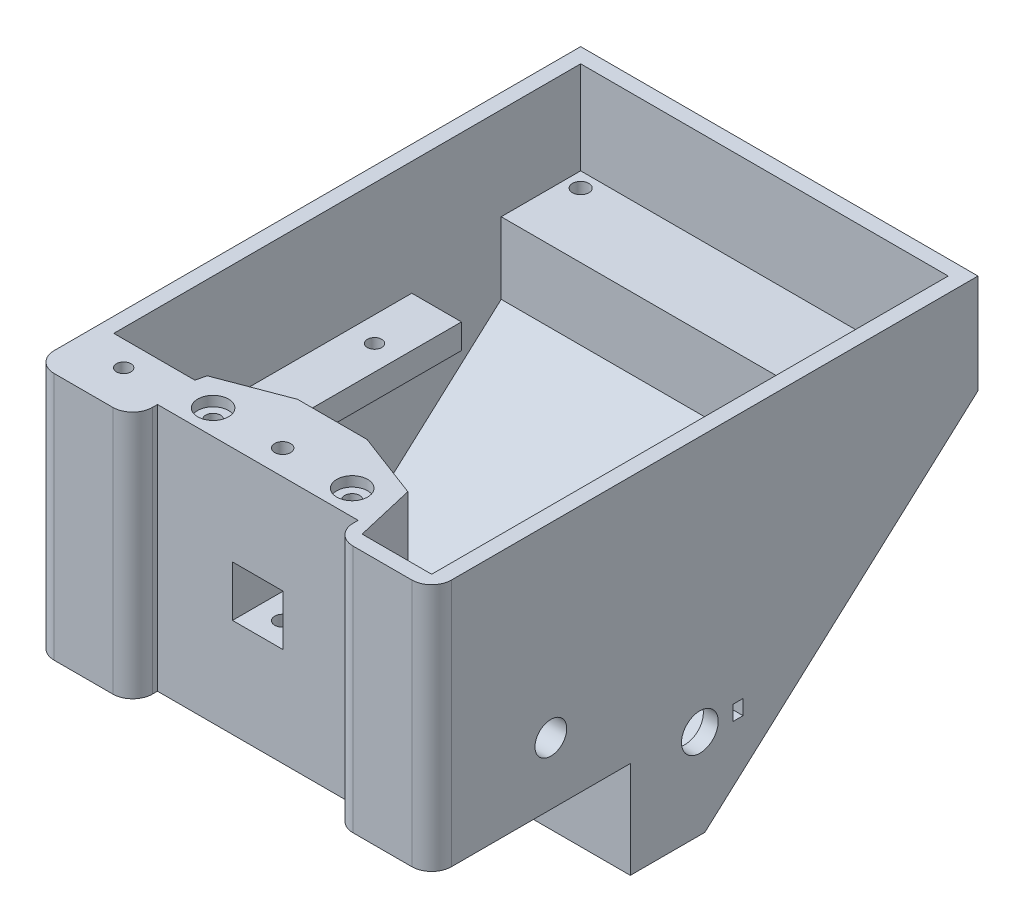
from build123d import *

# Parameters (mm, degrees)
BOSS_EXTRUDE1_DEPTH = 80
SHELL1_T            = -3
SKETCH3_W           = 46
SKETCH3_H           = 47
BOSS_EXTRUDE2_DEPTH = 17
SKETCH4_W           = 10.2
SKETCH4_H           = 10.2
CUT_EXTRUDE1_DEPTH  = 20
SKETCH6_W           = 15
SKETCH6_H           = 12.8
CUT_EXTRUDE2_DEPTH  = 3
SKETCH7_W           = 40.4
SKETCH7_H           = 50
CUT_EXTRUDE3_DEPTH  = 5
FILLET1_R           = 4
CUT_EXTRUDE7_DEPTH  = 47
SKETCH13_R          = 1.5
CUT_EXTRUDE8_DEPTH  = 25
SKETCH14_R          = 3.1
CUT_EXTRUDE9_DEPTH  = 2
SKETCH17_W          = 45
SKETCH17_H          = 5
BOSS_EXTRUDE5_DEPTH = 74
CUT_EXTRUDE10_REACH = 126.093
SKETCH18_W          = 54
SKETCH18_H          = 45
CUT_EXTRUDE11_REACH = 126.093
SKETCH19_R          = 1.45
BOSS_EXTRUDE6_DEPTH = 47
SKETCH22_R          = 1.45
CUT_EXTRUDE12_DEPTH = 135.415364765
CUT_EXTRUDE13_REACH = 126.857
SKETCH24_R          = 3.7
SKETCH24_W          = 2
SKETCH24_H          = 3
BOSS_EXTRUDE7_DEPTH = 74
SKETCH27_R          = 1.65
CUT_EXTRUDE14_DEPTH = 10
CUT_EXTRUDE15_START = -3
CUT_EXTRUDE15_DEPTH = 32
CUT_EXTRUDE16_DEPTH = 30
BOSS_EXTRUDE8_DEPTH = 20
SKETCH31_R          = 1.5
CUT_EXTRUDE17_DEPTH = 123.649786567
CUT_EXTRUDE18_DEPTH = 15
CUT_EXTRUDE19_REACH = 126.093
SKETCH33_W          = 10
SKETCH33_H          = 5
SKETCH34_R          = 1.6
CUT_EXTRUDE20_DEPTH = 135.415364765
CUT_EXTRUDE22_DEPTH = 14
CUT_EXTRUDE23_REACH = 126.857
SKETCH37_R          = 3.2
SKETCH38_W          = 10
SKETCH38_H          = 18.980735551
SKETCH38_R          = 3.2
BOSS_EXTRUDE9_DEPTH = 3


with BuildPart() as part:
    # Sketch2 → Boss-Extrude1 (new body)
    with BuildSketch(Plane(origin=(0, 0, 0), x_dir=(0, 0, -1), z_dir=(1, 0, 0))):
        Polygon((-27.320490368, 20.998248687), (-27.320490368, -29.001751313), (12.679509632, -29.001751313), (12.679509632, -48.511383538), (27.679509632, -48.511383538), (82.679509632, 0.998248687), (82.679509632, 20.998248687), align=None)
    extrude(amount=BOSS_EXTRUDE1_DEPTH)

    # Shell1
    shell1_openings = [part.faces().sort_by_distance(p)[0] for p in [
        (40, 20.998248687, -27.679509632),
    ]]
    offset(amount=SHELL1_T, openings=shell1_openings, kind=Kind.INTERSECTION)

    # Sketch3 → Boss-Extrude2 (add)
    with BuildSketch(Plane(origin=(0, 0, 24.320490368), x_dir=(-1, 0, 0), z_dir=(0, 0, -1))):
        with Locations((-40, -2.501751313)):
            Rectangle(SKETCH3_W, SKETCH3_H)
    extrude(amount=BOSS_EXTRUDE2_DEPTH)

    # Sketch4 → Cut-Extrude1 (cut)
    with BuildSketch(Plane.XY.offset(27.320490368)):
        with Locations((40, -4.001751313)):
            Rectangle(SKETCH4_W, SKETCH4_H)
    extrude(amount=-CUT_EXTRUDE1_DEPTH, mode=Mode.SUBTRACT)

    # Sketch6 → Cut-Extrude2 (cut)
    with BuildSketch(Plane.XZ.offset(29.001751313)):
        with Locations((51.5, 0.920490368)):
            Rectangle(SKETCH6_W, SKETCH6_H)
        with Locations((28.5, 0.920490368)):
            Rectangle(SKETCH6_W, SKETCH6_H)
    extrude(amount=-CUT_EXTRUDE2_DEPTH, mode=Mode.SUBTRACT)

    # Sketch7 → Cut-Extrude3 (cut)
    with BuildSketch(Plane.XY.offset(27.320490368)):
        with Locations((40, -4.001751313)):
            Rectangle(SKETCH7_W, SKETCH7_H)
    extrude(amount=-CUT_EXTRUDE3_DEPTH, mode=Mode.SUBTRACT)

    # Fillet1
    fillet1_edges = [part.edges().sort_by_distance(p)[0] for p in [
        (19.8, -4.001751313, 27.320490368),
        (60.2, -4.001751313, 27.320490368),
        (80, -4.001751313, 27.320490368),
        (0, -4.001751313, 27.320490368),
    ]]
    fillet(fillet1_edges, radius=FILLET1_R)

    # Sketch12 → Cut-Extrude7 (cut)
    with BuildSketch(Plane(origin=(0, 20.998248687, 0), x_dir=(1, 0, 0), z_dir=(0, 1, 0))):
        Polygon((33, -7.320490368), (19.8, -12.320490368), (17, -24.320490368), (17, -7.320490368), align=None)
        Polygon((47, -7.320490368), (63, -7.320490368), (63, -24.320490368), (60.2, -12.320490368), align=None)
    extrude(amount=-CUT_EXTRUDE7_DEPTH, mode=Mode.SUBTRACT)

    # Sketch13 → Cut-Extrude8 (cut)
    with BuildSketch(Plane(origin=(0, 20.998248687, 0), x_dir=(1, 0, 0), z_dir=(0, 1, 0))):
        with Locations(Location((26, -17.320490368, 0), (0, 0, 270))):
            Circle(SKETCH13_R)
        with Locations(Location((54, -17.320490368, 0), (0, 0, 270))):
            Circle(SKETCH13_R)
    extrude(amount=-CUT_EXTRUDE8_DEPTH, mode=Mode.SUBTRACT)

    # Sketch14 → Cut-Extrude9 (cut)
    with BuildSketch(Plane(origin=(0, 20.998248687, 0), x_dir=(1, 0, 0), z_dir=(0, 1, 0))):
        with Locations(Location((26, -17.320490368, 0), (0, 0, 270))):
            Circle(SKETCH14_R)
        with Locations(Location((54, -17.320490368, 0), (0, 0, 270))):
            Circle(SKETCH14_R)
    extrude(amount=-CUT_EXTRUDE9_DEPTH, mode=Mode.SUBTRACT)

    # Sketch17 → Boss-Extrude5 (add)
    with BuildSketch(Plane.ZY.offset(-77)):
        with Locations((-23.179509632, -4.501751313)):
            Rectangle(SKETCH17_W, SKETCH17_H)
    extrude(amount=BOSS_EXTRUDE5_DEPTH)

    # Sketch18 → Cut-Extrude10 (cut, up to next)
    with BuildSketch(Plane(origin=(0, -2.001751313, 0), x_dir=(1, 0, 0), z_dir=(0, 1, 0)), mode=Mode.PRIVATE) as cut_extrude10_sk1:
        with Locations((40, 23.179509632)):
            Rectangle(SKETCH18_W, SKETCH18_H)
    cut_extrude10_tool1 = extrude(cut_extrude10_sk1.sketch, amount=-CUT_EXTRUDE10_REACH, mode=Mode.PRIVATE) & part.part
    add(cut_extrude10_tool1.solids().sort_by_distance((40, -2.001751, -23.17951))[0], mode=Mode.SUBTRACT)

    # Sketch19 → Cut-Extrude11 (cut, up to next)
    with BuildSketch(Plane(origin=(0, -2.001751313, 0), x_dir=(1, 0, 0), z_dir=(0, 1, 0)), mode=Mode.PRIVATE) as cut_extrude11_sk1:
        with Locations(Location((72, 37.179509632, 0), (0, 0, 270))):
            Circle(SKETCH19_R)
    cut_extrude11_tool1 = extrude(cut_extrude11_sk1.sketch, amount=-CUT_EXTRUDE11_REACH, mode=Mode.PRIVATE) & part.part
    # Sketch19 → Cut-Extrude11 (cut, up to next)
    with BuildSketch(Plane(origin=(0, -2.001751313, 0), x_dir=(1, 0, 0), z_dir=(0, 1, 0)), mode=Mode.PRIVATE) as cut_extrude11_sk2:
        with Locations(Location((72, 6.179509632, 0), (0, 0, 270))):
            Circle(SKETCH19_R)
    cut_extrude11_tool2 = extrude(cut_extrude11_sk2.sketch, amount=-CUT_EXTRUDE11_REACH, mode=Mode.PRIVATE) & part.part
    # Sketch19 → Cut-Extrude11 (cut, up to next)
    with BuildSketch(Plane(origin=(0, -2.001751313, 0), x_dir=(1, 0, 0), z_dir=(0, 1, 0)), mode=Mode.PRIVATE) as cut_extrude11_sk3:
        with Locations(Location((8, 33.179509632, 0), (0, 0, 270))):
            Circle(SKETCH19_R)
    cut_extrude11_tool3 = extrude(cut_extrude11_sk3.sketch, amount=-CUT_EXTRUDE11_REACH, mode=Mode.PRIVATE) & part.part
    # Sketch19 → Cut-Extrude11 (cut, up to next)
    with BuildSketch(Plane(origin=(0, -2.001751313, 0), x_dir=(1, 0, 0), z_dir=(0, 1, 0)), mode=Mode.PRIVATE) as cut_extrude11_sk4:
        with Locations(Location((8, 6.179509632, 0), (0, 0, 270))):
            Circle(SKETCH19_R)
    cut_extrude11_tool4 = extrude(cut_extrude11_sk4.sketch, amount=-CUT_EXTRUDE11_REACH, mode=Mode.PRIVATE) & part.part
    add(cut_extrude11_tool1.solids().sort_by_distance((72, -2.001751, -37.17951))[0], mode=Mode.SUBTRACT)
    add(cut_extrude11_tool2.solids().sort_by_distance((72, -2.001751, -6.17951))[0], mode=Mode.SUBTRACT)
    add(cut_extrude11_tool3.solids().sort_by_distance((8, -2.001751, -33.17951))[0], mode=Mode.SUBTRACT)
    add(cut_extrude11_tool4.solids().sort_by_distance((8, -2.001751, -6.17951))[0], mode=Mode.SUBTRACT)

    # Sketch21 → Boss-Extrude6 (add)
    with BuildSketch(Plane(origin=(0, -26.001751313, 0), x_dir=(1, 0, 0), z_dir=(0, 1, 0))):
        Polygon((3, -24.320490368), (3, -14.320490368), (19.333333333, -14.320490368), (17, -24.320490368), align=None)
    extrude(amount=BOSS_EXTRUDE6_DEPTH)

    # Sketch22 → Cut-Extrude12 (cut, through all)
    with BuildSketch(Plane(origin=(0, 20.998248687, 0), x_dir=(1, 0, 0), z_dir=(0, 1, 0))):
        with Locations(Location((10, -19.320490368, 0), (0, 0, 270))):
            Circle(SKETCH22_R)
    extrude(amount=-CUT_EXTRUDE12_DEPTH, mode=Mode.SUBTRACT)

    # Sketch24 → Cut-Extrude13 (cut, up to next)
    with BuildSketch(Plane(origin=(80, 0, 0), x_dir=(0, 0, -1), z_dir=(1, 0, 0)), mode=Mode.PRIVATE) as cut_extrude13_sk1:
        with Locations((26.679509632, -30.511383538)):
            Circle(SKETCH24_R)
    cut_extrude13_tool1 = extrude(cut_extrude13_sk1.sketch, amount=-CUT_EXTRUDE13_REACH, mode=Mode.PRIVATE) & part.part
    # Sketch24 → Cut-Extrude13 (cut, up to next)
    with BuildSketch(Plane(origin=(80, 0, 0), x_dir=(0, 0, -1), z_dir=(1, 0, 0)), mode=Mode.PRIVATE) as cut_extrude13_sk2:
        with Locations((34.379509632, -30.511383538)):
            Rectangle(SKETCH24_W, SKETCH24_H)
    cut_extrude13_tool2 = extrude(cut_extrude13_sk2.sketch, amount=-CUT_EXTRUDE13_REACH, mode=Mode.PRIVATE) & part.part
    add(cut_extrude13_tool1.solids().sort_by_distance((80, -30.511384, -26.67951))[0], mode=Mode.SUBTRACT)
    add(cut_extrude13_tool2.solids().sort_by_distance((80, -30.511384, -34.37951))[0], mode=Mode.SUBTRACT)

    # Sketch26 → Boss-Extrude7 (add)
    with BuildSketch(Plane(origin=(3, 0, 0), x_dir=(0, 0, -1), z_dir=(1, 0, 0))):
        Polygon((79.679509632, 2.334161996), (63.679509632, 2.334161996), (63.679509632, -12.068640106), align=None)
    extrude(amount=BOSS_EXTRUDE7_DEPTH)

    # Sketch27 → Cut-Extrude14 (cut)
    with BuildSketch(Plane(origin=(0, 2.334161996, 0), x_dir=(1, 0, 0), z_dir=(0, 1, 0))):
        with Locations(Location((6, 76.679509632, 0), (0, 0, 270))):
            Circle(SKETCH27_R)
        with Locations(Location((74, 76.679509632, 0), (0, 0, 270))):
            Circle(SKETCH27_R)
    extrude(amount=-CUT_EXTRUDE14_DEPTH, mode=Mode.SUBTRACT)

    # Sketch28 → Cut-Extrude15 (cut)
    with BuildSketch(Plane(origin=(0, 2.334161996, 0), x_dir=(1, 0, 0), z_dir=(0, 1, 0)).offset(CUT_EXTRUDE15_START)):
        Polygon((74, 79.929509632), (71.185417438, 78.304509632), (71.185417438, 75.054509632), (74, 73.429509632), (76.814582562, 75.054509632), (76.814582562, 78.304509632), align=None)
        Polygon((6, 73.429509632), (8.814582562, 75.054509632), (8.814582562, 78.304509632), (6, 79.929509632), (3.185417438, 78.304509632), (3.185417438, 75.054509632), align=None)
    extrude(amount=-CUT_EXTRUDE15_DEPTH, mode=Mode.SUBTRACT)

    # Sketch29 → Cut-Extrude16 (cut)
    with BuildSketch(Plane.XZ.offset(29.001751313)):
        Polygon((7.185417438, 17.695490368), (10, 16.070490368), (12.814582562, 17.695490368), (12.814582562, 20.945490368), (10, 22.570490368), (7.185417438, 20.945490368), align=None)
    extrude(amount=-CUT_EXTRUDE16_DEPTH, mode=Mode.SUBTRACT)

    # Sketch30 → Boss-Extrude8 (add)
    with BuildSketch(Plane(origin=(0, -26.001751313, 0), x_dir=(1, 0, 0), z_dir=(0, 1, 0))):
        Polygon((77, -24.320490368), (63, -24.320490368), (60.2, -12.320490368), (77, -12.320490368), align=None)
    extrude(amount=BOSS_EXTRUDE8_DEPTH)

    # Sketch31 → Cut-Extrude17 (cut, through all)
    with BuildSketch(Plane(origin=(0, -6.001751313, 0), x_dir=(1, 0, 0), z_dir=(0, 1, 0))):
        with Locations(Location((72, -21.320490368, 0), (0, 0, 270))):
            Circle(SKETCH31_R)
    extrude(amount=-CUT_EXTRUDE17_DEPTH, mode=Mode.SUBTRACT)

    # Sketch32 → Cut-Extrude18 (cut)
    with BuildSketch(Plane.XZ.offset(29.001751313)):
        Polygon((72, 24.570490368), (69.185417438, 22.945490368), (69.185417438, 19.695490368), (72, 18.070490368), (74.814582562, 19.695490368), (74.814582562, 22.945490368), align=None)
    extrude(amount=-CUT_EXTRUDE18_DEPTH, mode=Mode.SUBTRACT)

    # Sketch33 → Cut-Extrude19 (cut, up to next)
    with BuildSketch(Plane(origin=(0, -2.001751313, 0), x_dir=(1, 0, 0), z_dir=(0, 1, 0)), mode=Mode.PRIVATE) as cut_extrude19_sk1:
        with Locations((72, 43.179509632)):
            Rectangle(SKETCH33_W, SKETCH33_H)
    cut_extrude19_tool1 = extrude(cut_extrude19_sk1.sketch, amount=-CUT_EXTRUDE19_REACH, mode=Mode.PRIVATE) & part.part
    add(cut_extrude19_tool1.solids().sort_by_distance((72, -2.001751, -43.17951))[0], mode=Mode.SUBTRACT)

    # Sketch34 → Cut-Extrude20 (cut, through all)
    with BuildSketch(Plane(origin=(0, 20.998248687, 0), x_dir=(1, 0, 0), z_dir=(0, 1, 0))):
        with Locations(Location((40, -17.320490368, 0), (0, 0, 270))):
            Circle(SKETCH34_R)
    extrude(amount=-CUT_EXTRUDE20_DEPTH, mode=Mode.SUBTRACT)

    # Sketch36 → Cut-Extrude22 (cut)
    with BuildSketch(Plane.XZ.offset(29.001751313)):
        Polygon((38.375, 20.13507293), (36.75, 17.320490368), (38.375, 14.505907805), (41.625, 14.505907805), (43.25, 17.320490368), (41.625, 20.13507293), align=None)
    extrude(amount=-CUT_EXTRUDE22_DEPTH, mode=Mode.SUBTRACT)

    # Sketch37 → Cut-Extrude23 (cut, up to next)
    with BuildSketch(Plane(origin=(80, 0, 0), x_dir=(0, 0, -1), z_dir=(1, 0, 0)), mode=Mode.PRIVATE) as cut_extrude23_sk1:
        with Locations((-3.320490368, -16.511383538)):
            Circle(SKETCH37_R)
    cut_extrude23_tool1 = extrude(cut_extrude23_sk1.sketch, amount=-CUT_EXTRUDE23_REACH, mode=Mode.PRIVATE) & part.part
    add(cut_extrude23_tool1.solids().sort_by_distance((80, -16.511384, 3.32049))[0], mode=Mode.SUBTRACT)

    # Sketch38 → Boss-Extrude9 (add)
    with BuildSketch(Plane.ZY.offset(-77)):
        with Locations((3.320490368, -16.511383538)):
            Rectangle(SKETCH38_W, SKETCH38_H)
        with Locations(Location((3.320490368, -16.511383538, 0), (0, 0, 180))):
            Circle(SKETCH38_R, mode=Mode.SUBTRACT)
    extrude(amount=BOSS_EXTRUDE9_DEPTH)


solid = part.part
